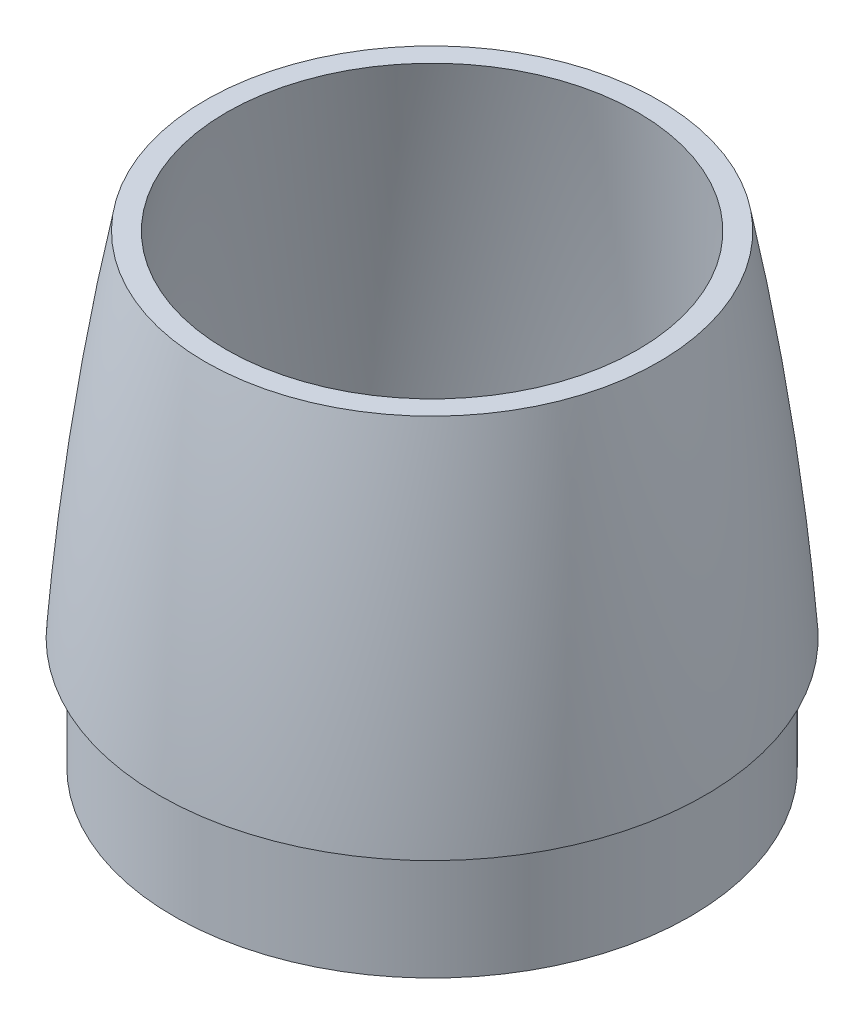
from build123d import *

# Parameters (mm, degrees)
SKETCH4_R           = 93.1545
SKETCH4_R_2         = 90.4875
BOSS_EXTRUDE2_DEPTH = 40.3999954
SKETCH7_R           = 317.5
CUT_EXTRUDE2_DEPTH  = 254


with BuildPart() as part:
    # Sketch2 → Revolve1 (revolve)
    with BuildSketch(Plane.XY):
        with BuildLine():
            Line((-98.425, 0), (-90.551, 0))
            ThreePointArc((-90.551, 0), (-60.43106349, 191.610647557), (0, 375.92))
            Line((0, 375.92), (0, 381))
            ThreePointArc((0, 381), (-66.494117829, 194.964417939), (-98.425, 0))
        make_face()
    revolve(axis=Axis((0, 381, 0), (0, -1, 0)))

    # Sketch4 → Boss-Extrude2 (add)
    with BuildSketch(Plane(origin=(0, 0, 0), x_dir=(-1, 0, 0), z_dir=(0, -1, 0))):
        Circle(SKETCH4_R)
        Circle(SKETCH4_R_2, mode=Mode.SUBTRACT)
    extrude(amount=BOSS_EXTRUDE2_DEPTH)

    # Sketch7 → Cut-Extrude2 (cut)
    with BuildSketch(Plane(origin=(0, 381, 0), x_dir=(1, 0, 0), z_dir=(0, 1, 0))):
        Circle(SKETCH7_R)
    extrude(amount=-CUT_EXTRUDE2_DEPTH, mode=Mode.SUBTRACT)


solid = part.part
